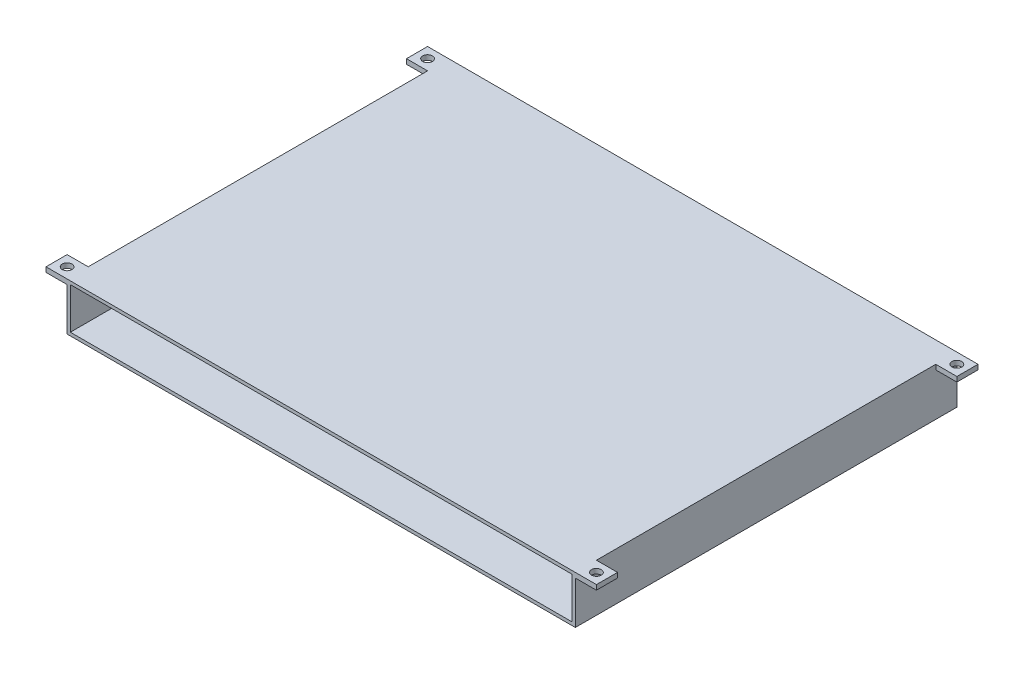
from build123d import *

# Parameters (mm, degrees)
BOSS_EXTRUDE1_DEPTH  = 2
BOSS_EXTRUDE2_DEPTH  = 2
BOSS_EXTRUDE3_DEPTH  = 2
BOSS_EXTRUDE4_DEPTH  = 200
BOSS_EXTRUDE5_DEPTH  = 2
SKETCH7_W            = 313
SKETCH7_H            = 235
BOSS_EXTRUDE6_DEPTH  = 2
SKETCH8_W            = 13
SKETCH8_H            = 3
BOSS_EXTRUDE10_DEPTH = 13
SKETCH9_R            = 3
CUT_EXTRUDE1_DEPTH   = 10


with BuildPart() as part:
    # Sketch2 → Boss-Extrude1 (new body)
    with BuildSketch(Plane.ZY.offset(188)):
        Polygon((-59, 12.7), (-57, 12.7), (0, 12.7), (0, 8.2), (0, -8.2), (0, -12.7), (-57, -12.7), (-59, -12.7), (-233, -12.7), (-233, 0), (-233, 9.7), (-233, 12.7), align=None)
    extrude(amount=BOSS_EXTRUDE1_DEPTH)

    # Sketch3 → Boss-Extrude2 (add)
    with BuildSketch(Plane(origin=(0, 12.7, 0), x_dir=(1, 0, 0), z_dir=(0, 1, 0))):
        Polygon((-190, 233), (-188, 233), (121, 233), (121, 59), (121, 0), (111, 0), (-190, 0), align=None)
    extrude(amount=BOSS_EXTRUDE2_DEPTH)

    # Sketch4 → Boss-Extrude3 (add)
    with BuildSketch(Plane(origin=(0, 0, -233), x_dir=(-1, 0, 0), z_dir=(0, 0, -1))):
        Polygon((-121, 14.7), (190, 14.7), (190, -12.7), (-111, -12.7), (-121, -12.7), (-121, 12.7), align=None)
    extrude(amount=BOSS_EXTRUDE3_DEPTH)

    # Sketch6 → Boss-Extrude5 (add)
    with BuildSketch(Plane(origin=(121, 0, 0), x_dir=(0, 0, -1), z_dir=(1, 0, 0))):
        Polygon((235, 14.7), (235, -12.7), (0, -12.7), (0, 12.7), (0, 14.7), align=None)
    extrude(amount=BOSS_EXTRUDE5_DEPTH)

    # Sketch7 → Boss-Extrude6 (add)
    with BuildSketch(Plane.XZ.offset(12.7)):
        with Locations((-33.5, -117.5)):
            Rectangle(SKETCH7_W, SKETCH7_H)
    extrude(amount=BOSS_EXTRUDE6_DEPTH)

    # Sketch8 → Boss-Extrude10 (add)
    with BuildSketch(Plane(origin=(123, 0, 0), x_dir=(0, 0, -1), z_dir=(1, 0, 0))):
        with Locations((6.5, 13.2)):
            Rectangle(SKETCH8_W, SKETCH8_H)
        with Locations((228.5, 13.2)):
            Rectangle(SKETCH8_W, SKETCH8_H)
    boss_extrude10 = extrude(amount=BOSS_EXTRUDE10_DEPTH)

    # Mirror1: Boss-Extrude10 across plane
    add(boss_extrude10.mirror(Plane.ZY.offset(33.5)))

    # Sketch9 → Cut-Extrude1 (cut)
    with BuildSketch(Plane.XZ.offset(-11.7)):
        with Locations((129.5, -228.5)):
            Circle(SKETCH9_R)
        with Locations((129.5, -6.5)):
            Circle(SKETCH9_R)
    cut_extrude1 = extrude(amount=-CUT_EXTRUDE1_DEPTH, mode=Mode.SUBTRACT)

    # Mirror2: Cut-Extrude1 across plane
    add(cut_extrude1.mirror(Plane.ZY.offset(33.5)), mode=Mode.SUBTRACT)


with BuildPart() as body_2:
    # Sketch5 → Boss-Extrude4 (new body)
    with BuildSketch(Plane(origin=(0, 0, -233), x_dir=(-1, 0, 0), z_dir=(0, 0, -1))):
        Polygon((27, 0), (27, -9.7), (37, -9.7), (37, 0), (37, 9.7), (27, 9.7), align=None)
    extrude(amount=-BOSS_EXTRUDE4_DEPTH)


solid = Compound([part.part, body_2.part])
